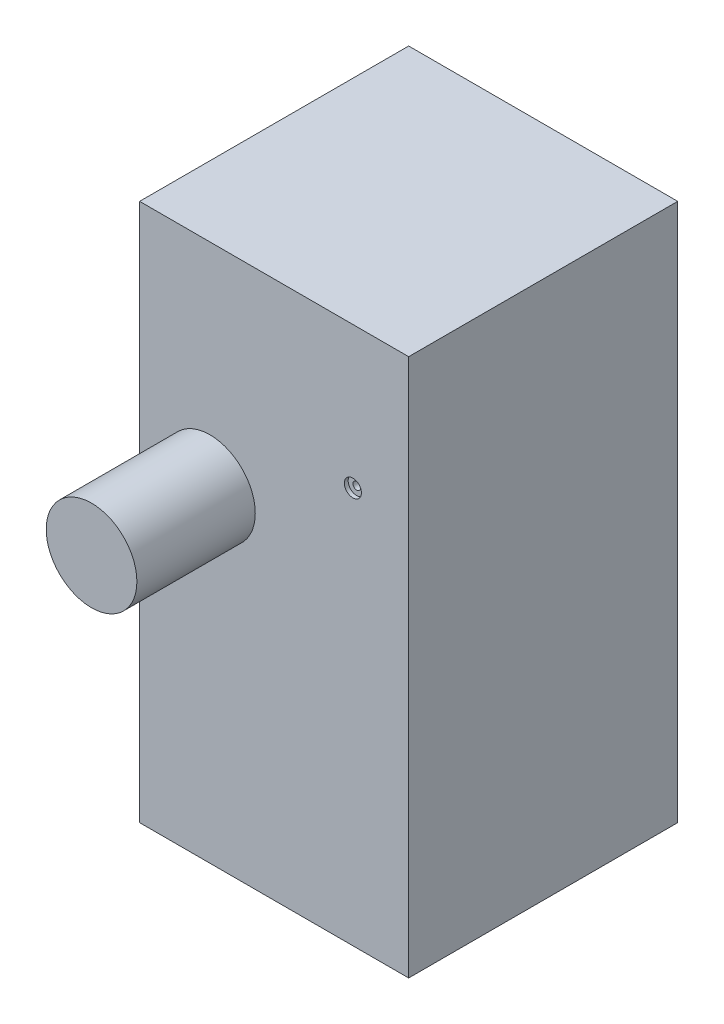
from build123d import *

# Parameters (mm, degrees)
SKETCH1_W                                           = 50
SKETCH1_H                                           = 50
BOSS_EXTRUDE1_DEPTH                                 = 100
SKETCH2_R                                           = 8.427155927
BOSS_EXTRUDE2_DEPTH                                 = 22
CBORE_FOR_00_BINDING_HEAD_MACHINE_SCREW_D           = 1.397
CBORE_FOR_00_BINDING_HEAD_MACHINE_SCREW_CBORE_D     = 3.175
CBORE_FOR_00_BINDING_HEAD_MACHINE_SCREW_CBORE_DEPTH = 0.7112


with BuildPart() as part:
    # Sketch1 → Boss-Extrude1 (new body)
    with BuildSketch(Plane(origin=(0, 0, 0), x_dir=(1, 0, 0), z_dir=(0, 1, 0))):
        with Locations((-25, 25)):
            Rectangle(SKETCH1_W, SKETCH1_H)
    extrude(amount=BOSS_EXTRUDE1_DEPTH)

    # Sketch2 → Boss-Extrude2 (add)
    with BuildSketch(Plane.XY):
        with Locations((-36.936942804, 60.539744496)):
            Circle(SKETCH2_R)
    extrude(amount=BOSS_EXTRUDE2_DEPTH)

    # CBORE for #00 Binding Head Machine Screw1 (through all)
    with Locations(Plane.XY):
        with Locations((-10.367880278, 73.678854219)):
            CounterBoreHole(CBORE_FOR_00_BINDING_HEAD_MACHINE_SCREW_D / 2, CBORE_FOR_00_BINDING_HEAD_MACHINE_SCREW_CBORE_D / 2, CBORE_FOR_00_BINDING_HEAD_MACHINE_SCREW_CBORE_DEPTH)


solid = part.part
